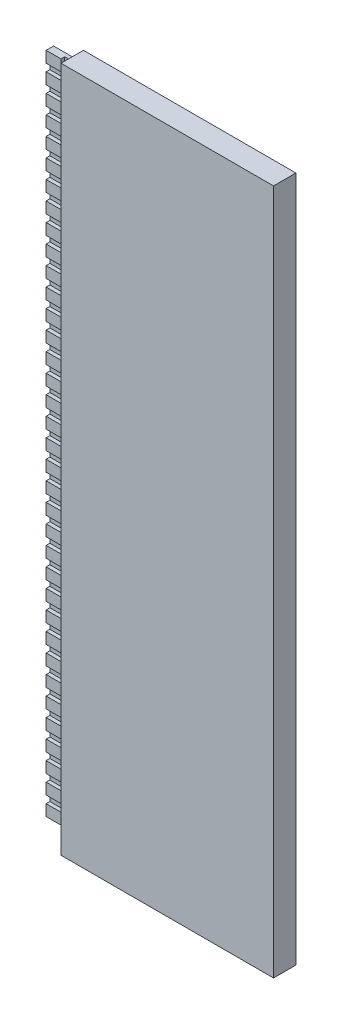
from build123d import *

# Parameters (mm, degrees)
SKETCH1_W       = 2.85
SKETCH1_H       = 9.2
EXTRUDE1_DEPTH  = 0.3
SKETCH2_W       = 0.4
SKETCH2_H       = 8.9
EXTRUDE2_DEPTH  = 0.05
SKETCH3_W       = 0.2
SKETCH3_H       = 8.9
EXTRUDE3_DEPTH  = 0.05
SKETCH4_W       = 0.2
SKETCH4_H       = 0.1
EXTRUDE4_DEPTH  = 1.25
LPATTERN1_COUNT = 35
LPATTERN1_PITCH = 0.25


with BuildPart() as part:
    # Sketch1 → Extrude1 (new body)
    with BuildSketch(Plane.XY):
        Rectangle(SKETCH1_W, SKETCH1_H)
    extrude(amount=EXTRUDE1_DEPTH)

    # Sketch2 → Extrude2 (add)
    with BuildSketch(Plane.XY):
        with Locations((-1.625, 0)):
            Rectangle(SKETCH2_W, SKETCH2_H)
    extrude(amount=EXTRUDE2_DEPTH)

    # Sketch3 → Extrude3 (add)
    with BuildSketch(Plane.XY.offset(0.05)):
        with Locations((-1.725, 0)):
            Rectangle(SKETCH3_W, SKETCH3_H)
    extrude(amount=EXTRUDE3_DEPTH)

    # Sketch4 → Extrude4 (cut, through all)
    with BuildSketch(Plane.XY.offset(0.05)):
        with Locations((-1.725, -4.25)):
            Rectangle(SKETCH4_W, SKETCH4_H)
    extrude4 = extrude(amount=EXTRUDE4_DEPTH, mode=Mode.SUBTRACT)

    # LPattern1: Extrude4 ×35
    with Locations(*[(0, i * LPATTERN1_PITCH, 0) for i in range(1, LPATTERN1_COUNT)]):
        add(extrude4, mode=Mode.SUBTRACT)


solid = part.part
